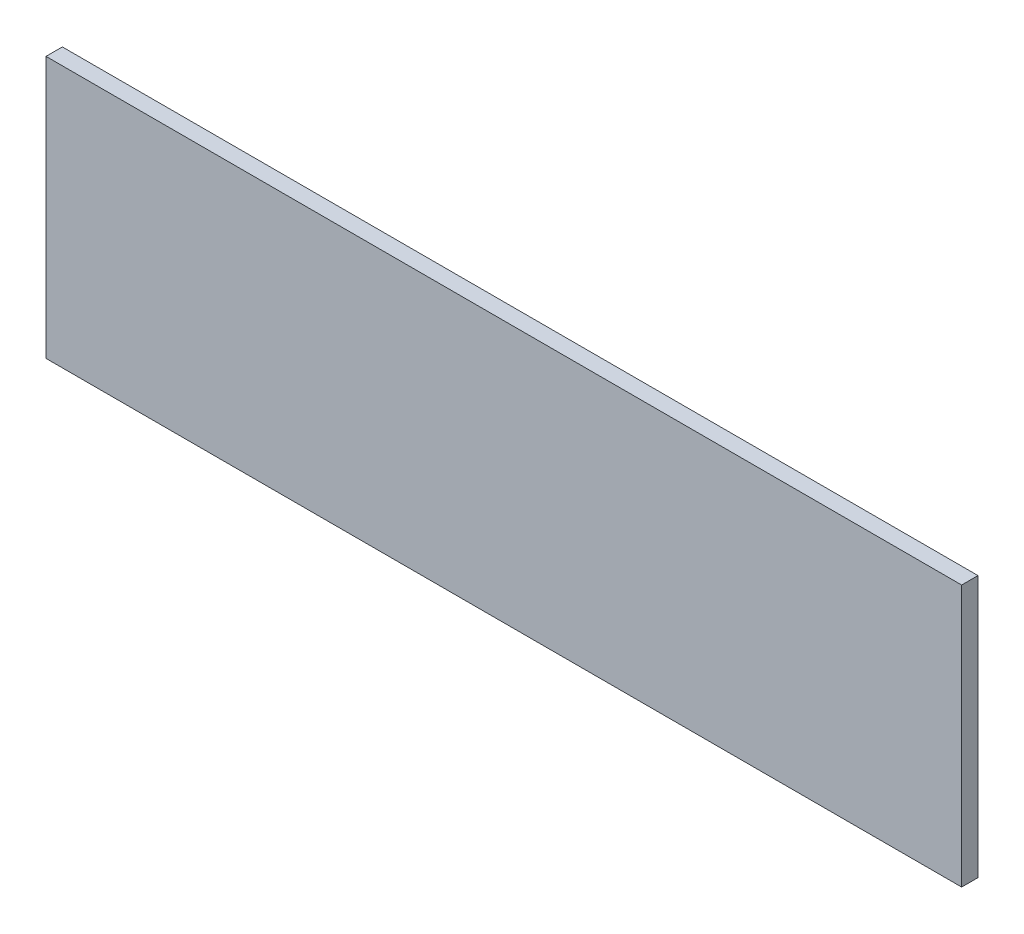
from build123d import *

# Parameters (mm, degrees)
SKETCH1_W           = 177.8
SKETCH1_H           = 50.8
BOSS_EXTRUDE1_DEPTH = 3.175


with BuildPart() as part:
    # Sketch1 → Boss-Extrude1 (new body)
    with BuildSketch(Plane.XY):
        with Locations((88.9, 25.4)):
            Rectangle(SKETCH1_W, SKETCH1_H)
    extrude(amount=BOSS_EXTRUDE1_DEPTH)


solid = part.part
